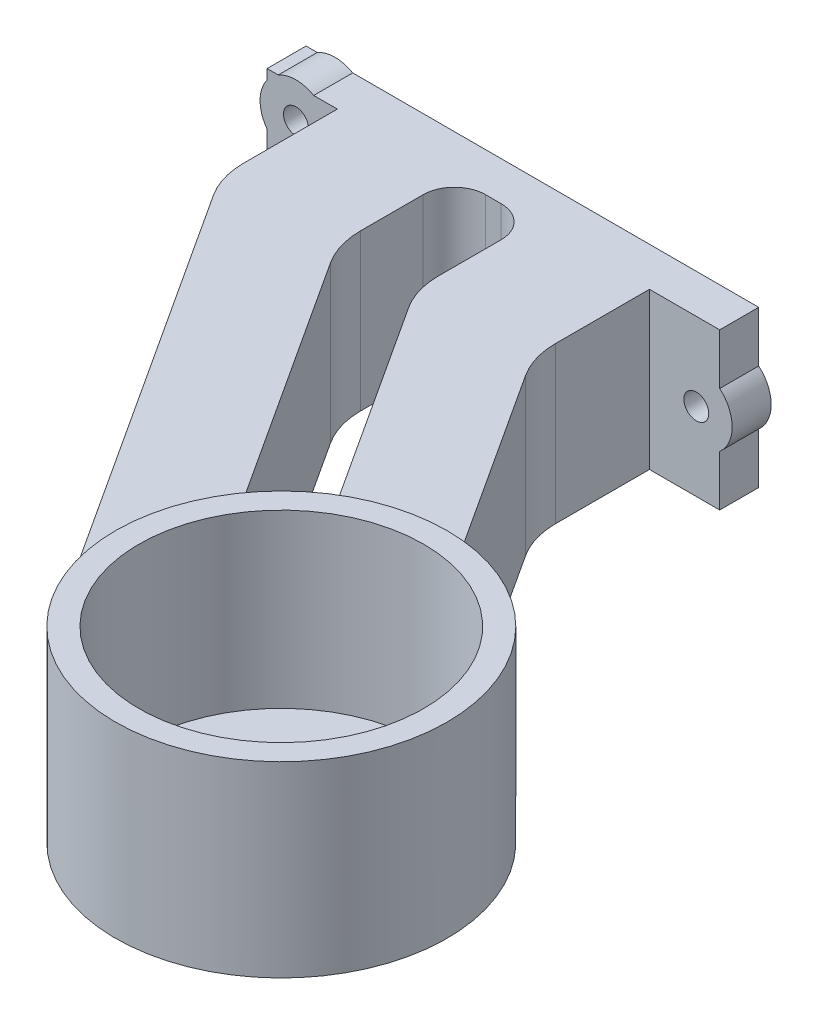
from build123d import *

# Parameters (mm, degrees)
SKETCH1_R           = 18.25
SKETCH1_R_2         = 1.6
SKETCH1_R_3         = 11.5
BOSS_EXTRUDE1_DEPTH = 2
SKETCH1_3_R         = 21.25
SKETCH1_3_R_2       = 18.25
BOSS_EXTRUDE2_DEPTH = 24
BOSS_EXTRUDE3_DEPTH = 20
SKETCH3_R           = 1.6
BOSS_EXTRUDE4_DEPTH = 5
FILLET3_R           = 10
FILLET4_R           = 4


with BuildPart() as part:
    # Sketch1 → Boss-Extrude1 (new body)
    with BuildSketch(Plane(origin=(0, 0, 0), x_dir=(1, 0, 0), z_dir=(0, 1, 0))):
        Circle(SKETCH1_R)
        with Locations((-14, 0)):
            Circle(SKETCH1_R_2, mode=Mode.SUBTRACT)
        with Locations((0, -14)):
            Circle(SKETCH1_R_2, mode=Mode.SUBTRACT)
        Circle(SKETCH1_R_3, mode=Mode.SUBTRACT)
        with Locations((14, 0)):
            Circle(SKETCH1_R_2, mode=Mode.SUBTRACT)
        with Locations((0, 14)):
            Circle(SKETCH1_R_2, mode=Mode.SUBTRACT)
    extrude(amount=BOSS_EXTRUDE1_DEPTH)

    # Sketch1_3 → Boss-Extrude2 (add)
    with BuildSketch(Plane(origin=(0, 0, 0), x_dir=(1, 0, 0), z_dir=(0, 1, 0))):
        Circle(SKETCH1_3_R)
        Circle(SKETCH1_3_R_2, mode=Mode.SUBTRACT)
    extrude(amount=BOSS_EXTRUDE2_DEPTH)

    # Sketch2 → Boss-Extrude3 (add)
    with BuildSketch(Plane(origin=(0, 0, 0), x_dir=(1, 0, 0), z_dir=(0, 1, 0))):
        with BuildLine():
            ThreePointArc((-17.839967658, -11.545477642), (-21.249992199, 0.018208346), (-17.820155675, 11.576033506))
            Line((-17.820155675, 11.576033506), (-57.820155675, -50))
            Line((-57.820155675, -50), (-57.820155675, -70))
            Line((-57.820155675, -70), (-42.820155675, -70))
            Line((-42.820155675, -70), (-42.820155675, -50))
            Line((-42.820155675, -50), (-17.839967658, -11.545477642))
        make_face()
        with BuildLine():
            Line((-17.820155675, -50), (0.867447809, -21.232287543))
            ThreePointArc((0.867447809, -21.232287543), (-5.756886716, -20.45533562), (-11.81408432, -17.663236161))
            Line((-11.81408432, -17.663236161), (-32.820155675, -50))
            Line((-32.820155675, -50), (-32.820155675, -70))
            Line((-32.820155675, -70), (-17.820155675, -70))
            Line((-17.820155675, -70), (-17.820155675, -50))
        make_face()
    extrude(amount=BOSS_EXTRUDE3_DEPTH)

    # Sketch3 → Boss-Extrude4 (add)
    with BuildSketch(Plane.XY.offset(70)):
        with BuildLine():
            Line((-65.389940295, 20), (-66.820155675, 20))
            Line((-66.820155675, 20), (-66.820155675, 18.730720476))
            ThreePointArc((-66.820155675, 18.730720476), (-67.718376956, 16), (-66.820155675, 13.269279524))
            Line((-66.820155675, 13.269279524), (-66.820155675, 6.730720476))
            ThreePointArc((-66.820155675, 6.730720476), (-67.718376956, 4), (-66.820155675, 1.269279524))
            Line((-66.820155675, 1.269279524), (-66.820155675, 0))
            Line((-66.820155675, 0), (-65.389940295, 0))
            ThreePointArc((-65.389940295, 0), (-63.118376956, -0.6), (-60.846813618, 0))
            Line((-60.846813618, 0), (-8.820155675, 0))
            Line((-8.820155675, 0), (-8.820155675, 6.512880845))
            ThreePointArc((-8.820155675, 6.512880845), (-7.220155675, 10), (-8.820155675, 13.487119155))
            Line((-8.820155675, 13.487119155), (-8.820155675, 20))
            Line((-8.820155675, 20), (-60.846813618, 20))
            ThreePointArc((-60.846813618, 20), (-63.118376956, 20.6), (-65.389940295, 20))
        make_face()
        with Locations((-63.118376956, 16)):
            Circle(SKETCH3_R, mode=Mode.SUBTRACT)
        with Locations((-11.820155675, 10)):
            Circle(SKETCH3_R, mode=Mode.SUBTRACT)
        with Locations((-63.118376956, 4)):
            Circle(SKETCH3_R, mode=Mode.SUBTRACT)
    extrude(amount=-BOSS_EXTRUDE4_DEPTH)

    # Fillet3
    fillet3_edges = [part.edges().sort_by_distance(p)[0] for p in [
        (-57.820155675, 10, 50),
        (-32.820155675, 10, 50),
        (-42.820155675, 10, 50),
        (-17.820155675, 10, 50),
    ]]
    fillet(fillet3_edges, radius=FILLET3_R)

    # Fillet4
    fillet4_edges = [part.edges().sort_by_distance(p)[0] for p in [
        (-42.820155675, 10, 65),
        (-32.820155675, 10, 65),
        (-17.839967658, 10, 11.545477642),
        (0.867447809, 10, 21.232287543),
        (-11.81408432, 10, 17.663236161),
    ]]
    fillet(fillet4_edges, radius=FILLET4_R)


with BuildPart() as body_2:
    # Mirror1: mirrored copy
    add(part.part.mirror(Plane(origin=(0, 20, 70), x_dir=(1, 0, 0), z_dir=(0, 0, -1))))


solid = body_2.part
